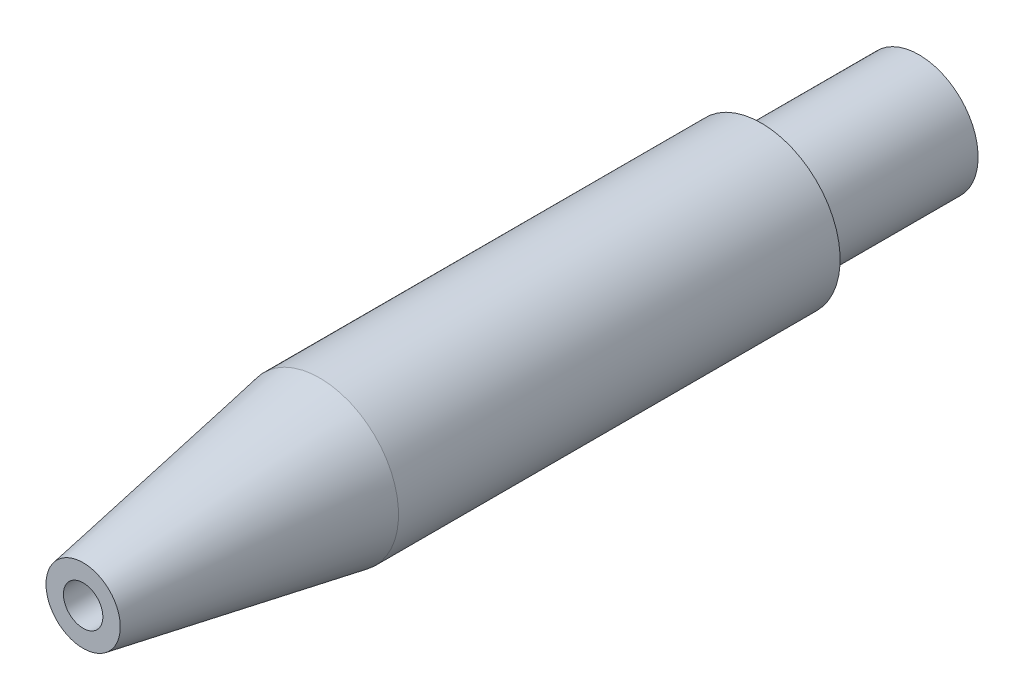
from build123d import *

# Parameters (mm, degrees)
SKETCH1_R                       = 6.35
BOSS_EXTRUDE1_DEPTH             = 67.31
SKETCH8_R                       = 1.5875
CUT_EXTRUDE1_DEPTH              = 68.31
SKETCH10_R                      = 6.35
SKETCH10_R_2                    = 4.7625
CUT_EXTRUDE2_DEPTH              = 12.7
F_1_4_0_25_DIAMETER_HOLE1_D     = 6.5278
F_1_4_0_25_DIAMETER_HOLE1_DEPTH = 59.69
F_1_4_0_25_DIAMETER_HOLE1_TIP   = 1.961148974


with BuildPart() as part:
    # Sketch1 → Boss-Extrude1 (new body)
    with BuildSketch(Plane.XY):
        Circle(SKETCH1_R)
    extrude(amount=BOSS_EXTRUDE1_DEPTH)

    # Sketch7 → Cut-Revolve1 (revolve, cut)
    with BuildSketch(Plane(origin=(0, 0, 0), x_dir=(1, 0, 0), z_dir=(0, 1, 0))):
        Polygon((6.35, -67.31), (6.35, -48.26), (2.990971018, -67.31), align=None)
    revolve(axis=Axis((0, 0, -47.573976859), (0, 0, 1)), mode=Mode.SUBTRACT)

    # Sketch8 → Cut-Extrude1 (cut, through all)
    with BuildSketch(Plane.XY.offset(67.31)):
        Circle(SKETCH8_R)
    extrude(amount=-CUT_EXTRUDE1_DEPTH, mode=Mode.SUBTRACT)

    # Sketch10 → Cut-Extrude2 (cut)
    with BuildSketch(Plane(origin=(0, 0, 0), x_dir=(-1, 0, 0), z_dir=(0, 0, -1))):
        Circle(SKETCH10_R)
        Circle(SKETCH10_R_2, mode=Mode.SUBTRACT)
    extrude(amount=-CUT_EXTRUDE2_DEPTH, mode=Mode.SUBTRACT)

    # 1/4 (0.25) Diameter Hole1
    with Locations(Plane(origin=(0, 0, 0), x_dir=(-1, 0, 0), z_dir=(0, 0, -1))):
        with Locations((0, 0)):
            Hole(F_1_4_0_25_DIAMETER_HOLE1_D / 2, depth=F_1_4_0_25_DIAMETER_HOLE1_DEPTH)
            with Locations((0, 0, -(F_1_4_0_25_DIAMETER_HOLE1_DEPTH + F_1_4_0_25_DIAMETER_HOLE1_TIP / 2))):  # 118° drill point
                Cone(0, F_1_4_0_25_DIAMETER_HOLE1_D / 2, F_1_4_0_25_DIAMETER_HOLE1_TIP, mode=Mode.SUBTRACT)


solid = part.part
